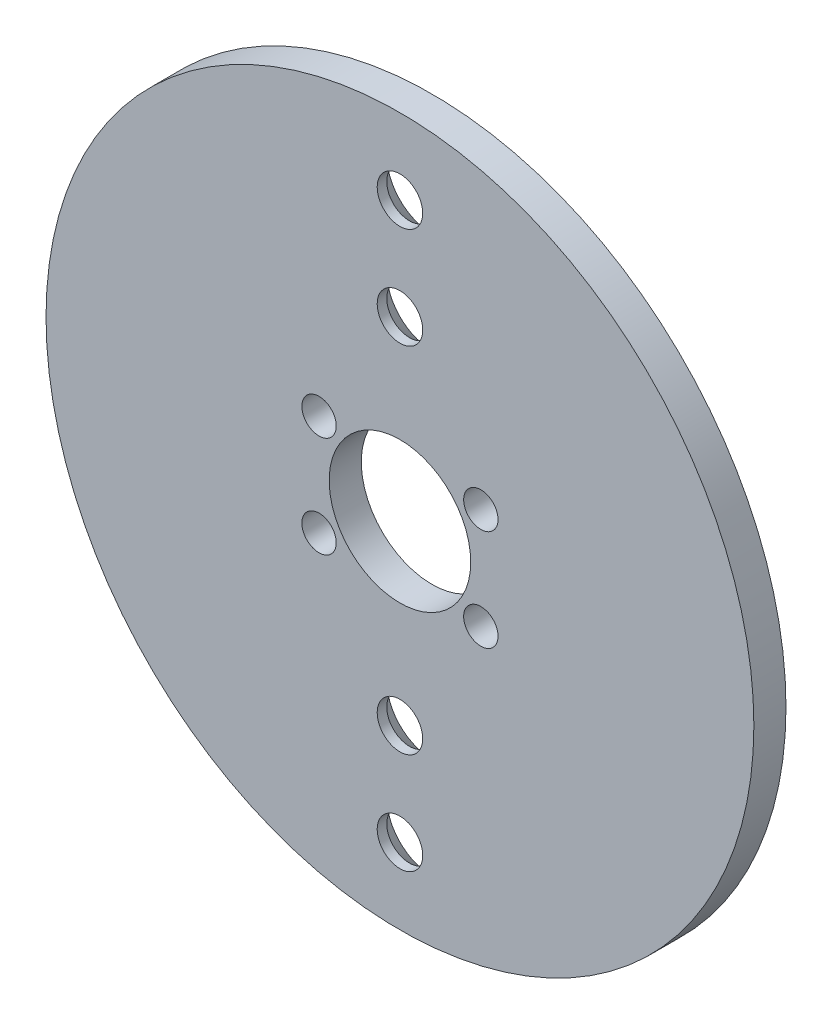
from build123d import *

# Parameters (mm, degrees)
SKETCH2_R                    = 35
BOSS_EXTRUDE1_DEPTH          = 1.5875
SKETCH3_R                    = 7
CUT_EXTRUDE1_DEPTH           = 4.175
M3_CLEARANCE_HOLE1_D         = 3.4
CSK_FOR_M4_SFHCS1_AT_2_COUNT = 2
CSK_FOR_M4_SFHCS1_AT_2_PITCH = 10
CSK_FOR_M4_SFHCS1_AT_3_COUNT = 2
CSK_FOR_M4_SFHCS1_AT_3_PITCH = 45
CSK_FOR_M4_SFHCS1_AT_4_COUNT = 2
CSK_FOR_M4_SFHCS1_AT_4_PITCH = 55


with BuildPart() as part:
    # Sketch2 → Boss-Extrude1 (new body, symmetric)
    with BuildSketch(Plane.XY):
        Circle(SKETCH2_R)
    extrude(amount=BOSS_EXTRUDE1_DEPTH, both=True)

    # Sketch3 → Cut-Extrude1 (cut, through all)
    with BuildSketch(Plane.XY.offset(1.5875)):
        Circle(SKETCH3_R)
    extrude(amount=-CUT_EXTRUDE1_DEPTH, mode=Mode.SUBTRACT)

    # M3 Clearance Hole1 (through all)
    with Locations(Plane.XY.offset(1.5875)):
        with Locations((8, 5), (8, -5), (-8, 5), (-8, -5)):
            Hole(M3_CLEARANCE_HOLE1_D / 2)

    # Sketch8 → CSK for M4 SFHCS1 (revolve, cut)
    with BuildSketch(Plane(origin=(2.358e-06, 27.5, -1.5875), x_dir=(0, 1, 0), z_dir=(1, 0, 0))):
        Polygon((0, 0), (0, 3.175), (2.25, 3.175), (2.25, 2.23), (4.48, 0), align=None)
    csk_for_m4_sfhcs1 = revolve(axis=Axis((2.358e-06, 27.5, -7.9375), (0, 0, 1)), mode=Mode.SUBTRACT)

    # CSK for M4 SFHCS1 at 2: CSK for M4 SFHCS1 ×2
    with Locations(*[(0, -i * CSK_FOR_M4_SFHCS1_AT_2_PITCH, 0) for i in range(1, CSK_FOR_M4_SFHCS1_AT_2_COUNT)]):
        add(csk_for_m4_sfhcs1, mode=Mode.SUBTRACT)

    # CSK for M4 SFHCS1 at 3: CSK for M4 SFHCS1 ×2
    with Locations(*[(0, -i * CSK_FOR_M4_SFHCS1_AT_3_PITCH, 0) for i in range(1, CSK_FOR_M4_SFHCS1_AT_3_COUNT)]):
        add(csk_for_m4_sfhcs1, mode=Mode.SUBTRACT)

    # CSK for M4 SFHCS1 at 4: CSK for M4 SFHCS1 ×2
    with Locations(*[(0, -i * CSK_FOR_M4_SFHCS1_AT_4_PITCH, 0) for i in range(1, CSK_FOR_M4_SFHCS1_AT_4_COUNT)]):
        add(csk_for_m4_sfhcs1, mode=Mode.SUBTRACT)


solid = part.part
